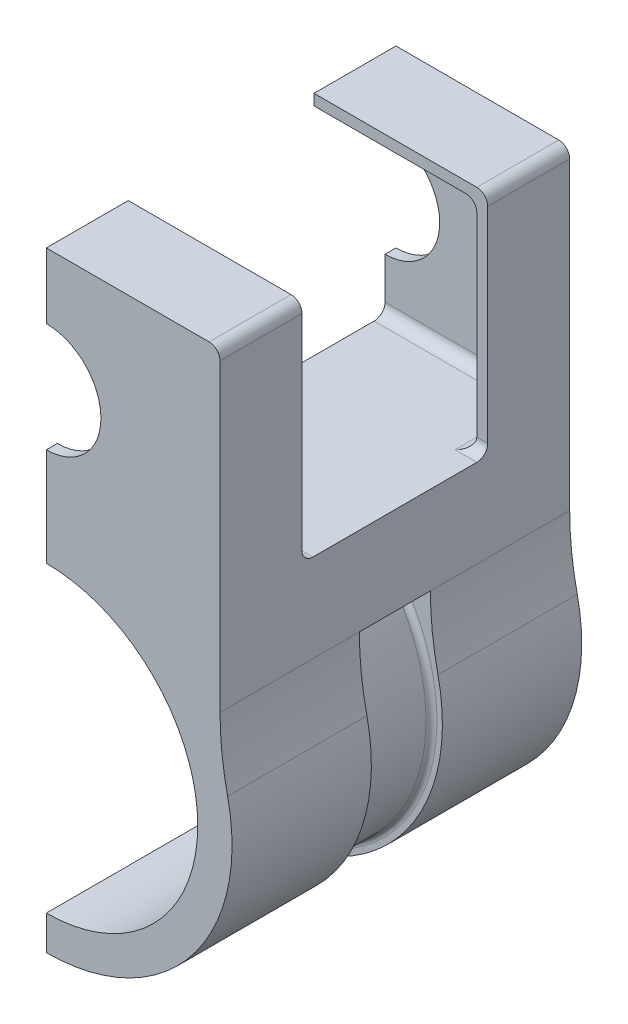
from build123d import *

# Parameters (mm, degrees)
BOSS_EXTRUDE1_DEPTH            = 81.28
SKETCH3_W                      = 76.2
SKETCH3_H                      = 50.292
CUT_EXTRUDE1_DEPTH             = 37.846
SKETCH4_W                      = 40.386
SKETCH4_H                      = 43.18
CUT_EXTRUDE2_DEPTH             = 52.832
FILLET1_R                      = 2.54
FILLET2_R                      = 2.54
FILLET3_R                      = 2.54
FILLET4_R                      = 2.54
SKETCH7_W                      = 16.51
SKETCH7_H                      = 2.54
CUT_EXTRUDE4_REACH             = 54.566
SKETCH8_W                      = 16.51
SKETCH8_H                      = 16.012242806
CUT_EXTRUDE4_DIRECTION_2_DEPTH = 2.54
FILLET5_R                      = 1.27


with BuildPart() as part:
    # Sketch1 → Boss-Extrude1 (new body)
    with BuildSketch(Plane.XY):
        with BuildLine():
            Line((0, 52.9844), (0, 58.0644))
            ThreePointArc((0, 58.0644), (12.7, 70.7644), (0, 83.4644))
            Line((0, 83.4644), (0, 98.7044))
            Line((0, 98.7044), (40.386, 98.7044))
            Line((40.386, 98.7044), (40.386, 25.398729968))
            ThreePointArc((40.386, 25.398729968), (40.827682914, 17.344312358), (42.147434783, 9.386487162))
            ThreePointArc((42.147434783, 9.386487162), (33.688432107, -27.011144777), (0, -43.18))
            Line((0, -43.18), (0, -35.2044))
            ThreePointArc((0, -35.2044), (35.2044, 0), (0, 35.2044))
            Line((0, 35.2044), (0, 52.9844))
        make_face()
    extrude(amount=-BOSS_EXTRUDE1_DEPTH)

    # Sketch3 → Cut-Extrude1 (cut)
    with BuildSketch(Plane.ZY):
        with Locations((-40.64, 71.0184)):
            Rectangle(SKETCH3_W, SKETCH3_H)
    extrude(amount=-CUT_EXTRUDE1_DEPTH, mode=Mode.SUBTRACT)

    # Sketch4 → Cut-Extrude2 (cut)
    with BuildSketch(Plane(origin=(0, 98.7044, 0), x_dir=(1, 0, 0), z_dir=(0, 1, 0))):
        with Locations((20.193, 40.64)):
            Rectangle(SKETCH4_W, SKETCH4_H)
    extrude(amount=-CUT_EXTRUDE2_DEPTH, mode=Mode.SUBTRACT)

    # Fillet1
    fillet1_edges = [part.edges().sort_by_distance(p)[0] for p in [
        (18.923, 45.8724, -78.74),
        (18.923, 45.8724, -2.54),
        (37.846, 45.8724, -10.795),
        (37.846, 45.8724, -70.485),
    ]]
    fillet(fillet1_edges, radius=FILLET1_R)

    # Fillet2
    fillet2_edges = [part.edges().sort_by_distance(p)[0] for p in [
        (37.846, 96.1644, -70.485),
        (37.846, 96.1644, -10.795),
    ]]
    fillet(fillet2_edges, radius=FILLET2_R)

    # Fillet3
    fillet3_edges = [part.edges().sort_by_distance(p)[0] for p in [
        (36.576, 45.8724, -19.05),
        (36.576, 45.8724, -62.23),
    ]]
    fillet(fillet3_edges, radius=FILLET3_R)

    # Fillet4
    fillet4_edges = [part.edges().sort_by_distance(p)[0] for p in [
        (40.386, 98.7044, -71.755),
        (40.386, 98.7044, -9.525),
    ]]
    fillet(fillet4_edges, radius=FILLET4_R)

    # Sketch7 → Cut-Revolve2 (revolve, cut)
    with BuildSketch(Plane.ZY):
        with Locations((-40.64, -41.91)):
            Rectangle(SKETCH7_W, SKETCH7_H)
    revolve(axis=Axis((0, 0, -81.28), (0, 0, 1)), mode=Mode.SUBTRACT)

    # Sketch8 → Cut-Extrude4 (cut, up to next)
    with BuildSketch(Plane(origin=(42.147434783, 9.386487162, 0), x_dir=(0, 0, -1), z_dir=(0.976086957, 0.217380435, 0)), mode=Mode.PRIVATE) as cut_extrude4_sk1:
        with Locations((40.64, 8.006121403)):
            Rectangle(SKETCH8_W, SKETCH8_H)
    cut_extrude4_tool1 = extrude(cut_extrude4_sk1.sketch, amount=-CUT_EXTRUDE4_REACH, mode=Mode.PRIVATE) & part.part
    add(cut_extrude4_tool1.solids().sort_by_distance((40.407061, 17.201158, -40.64))[0], mode=Mode.SUBTRACT)

    # Sketch8 → Cut-Extrude4 direction 2 (cut)
    with BuildSketch(Plane(origin=(42.147434783, 9.386487162, 0), x_dir=(0, 0, -1), z_dir=(0.976086957, 0.217380435, 0))):
        with Locations((40.64, 8.006121403)):
            Rectangle(SKETCH8_W, SKETCH8_H)
    extrude(amount=CUT_EXTRUDE4_DIRECTION_2_DEPTH, mode=Mode.SUBTRACT)

    # Fillet5
    fillet5_edges = [part.edges().sort_by_distance(p)[0] for p in [
        (40.64, 0, -48.895),
        (40.64, 0, -32.385),
    ]]
    fillet(fillet5_edges, radius=FILLET5_R)


solid = part.part
